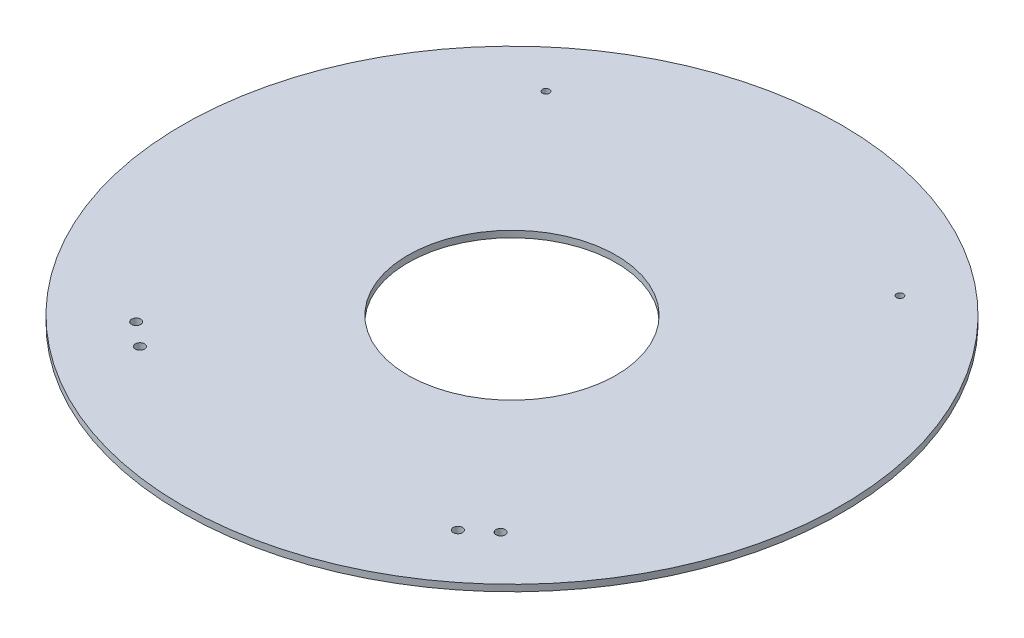
from build123d import *

# Parameters (mm, degrees)
SKETCH1_R               = 241.3
SKETCH1_R_2             = 76.2
BOSS_EXTRUDE1_DEPTH     = 4.7625
F_1_4_CLEARANCE_HOLE1_D = 6.7564
F_10_CLEARANCE_HOLE1_D  = 5.1054


with BuildPart() as part:
    # Sketch1 → Boss-Extrude1 (new body)
    with BuildSketch(Plane(origin=(0, 0, 0), x_dir=(1, 0, 0), z_dir=(0, 1, 0))):
        Circle(SKETCH1_R)
        Circle(SKETCH1_R_2, mode=Mode.SUBTRACT)
    extrude(amount=BOSS_EXTRUDE1_DEPTH)

    # 1/4 Clearance Hole1 (through all)
    with Locations(Plane(origin=(0, 0, 0), x_dir=(-1, 0, 0), z_dir=(0, -1, 0))):
        with Locations((133.426417095, -141.723430894), (-133.426417095, -141.723430894), (-116.401079347, -156.009385519), (116.401079347, -156.009385519)):
            Hole(F_1_4_CLEARANCE_HOLE1_D / 2)

    # #10 Clearance Hole1 (through all)
    with Locations(Plane(origin=(0, 0, 0), x_dir=(-1, 0, 0), z_dir=(0, -1, 0))):
        with Locations((-129.594016958, 154.444135288), (129.594016958, 154.444135288)):
            Hole(F_10_CLEARANCE_HOLE1_D / 2)


solid = part.part
